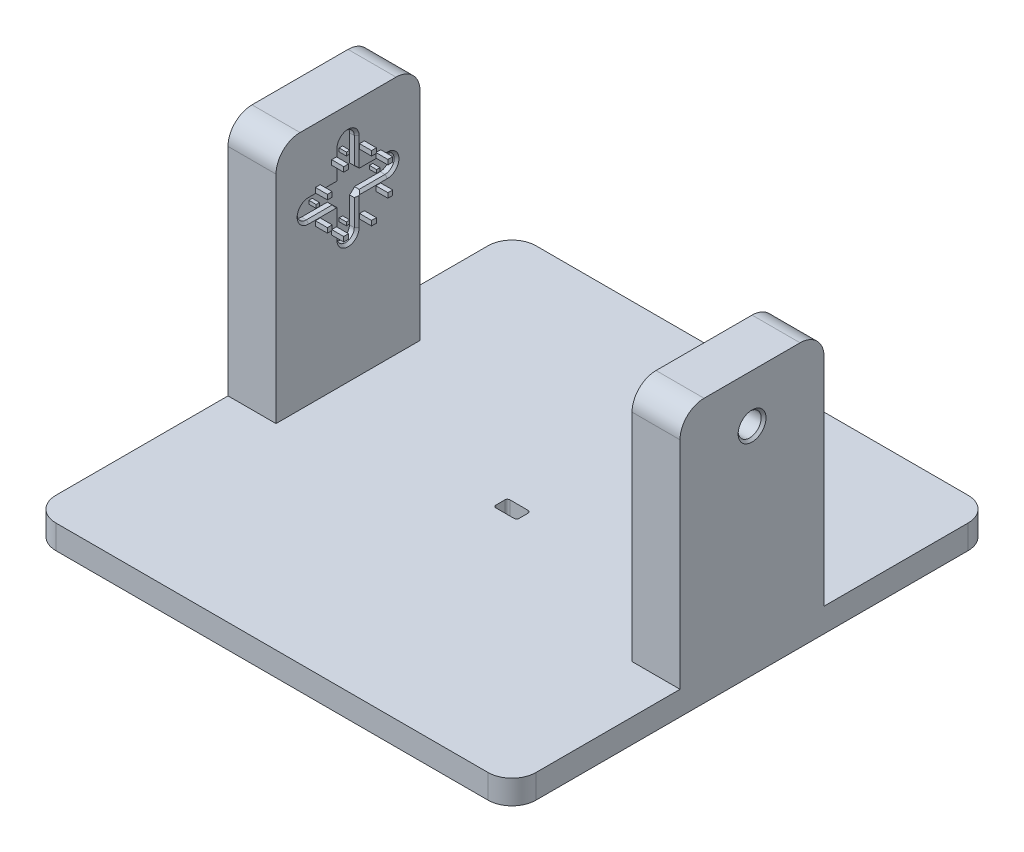
from build123d import *

# Parameters (mm, degrees)
SKETCH1_W           = 100
SKETCH1_H           = 100
BOSS_EXTRUDE1_DEPTH = 5
SKETCH2_W           = 10
SKETCH2_H           = 30
BOSS_EXTRUDE2_DEPTH = 50
CUT_EXTRUDE2_DEPTH  = 6
FILLET1_R           = 5
FILLET2_R           = 5
SKETCH7_W           = 0.707106782
SKETCH7_H           = 0.707106782
CUT_EXTRUDE3_DEPTH  = 1.5
SKETCH10_R          = 2.4
CUT_EXTRUDE4_DEPTH  = 11
CHAMFER1_SIZE       = 0.5
CHAMFER2_SIZE       = 0.5
CHAMFER3_SIZE       = 0.5
SKETCH11_W          = 1
SKETCH11_H          = 1
BOSS_EXTRUDE3_DEPTH = 2.5


with BuildPart() as part:
    # Sketch1 → Boss-Extrude1 (new body)
    with BuildSketch(Plane(origin=(0, 0, 0), x_dir=(1, 0, 0), z_dir=(0, 1, 0))):
        Rectangle(SKETCH1_W, SKETCH1_H)
    extrude(amount=BOSS_EXTRUDE1_DEPTH)

    # Sketch2 → Boss-Extrude2 (add)
    with BuildSketch(Plane(origin=(0, 5, 0), x_dir=(1, 0, 0), z_dir=(0, 1, 0))):
        with Locations((-45, 5.85)):
            Rectangle(SKETCH2_W, SKETCH2_H)
        with Locations((45, 0)):
            Rectangle(SKETCH2_W, SKETCH2_H)
    extrude(amount=BOSS_EXTRUDE2_DEPTH)

    # Sketch4 → Cut-Extrude2 (cut, through all)
    with BuildSketch(Plane(origin=(0, 5, 0), x_dir=(1, 0, 0), z_dir=(0, 1, 0))):
        with BuildLine():
            Line((-1.91, -1.46), (1.91, -1.46))
            ThreePointArc((1.91, -1.46), (2.263553391, -1.313553391), (2.41, -0.96))
            Line((2.41, -0.96), (2.41, 0.96))
            ThreePointArc((2.41, 0.96), (2.263553391, 1.313553391), (1.91, 1.46))
            Line((1.91, 1.46), (-1.91, 1.46))
            ThreePointArc((-1.91, 1.46), (-2.263553391, 1.313553391), (-2.41, 0.96))
            Line((-2.41, 0.96), (-2.41, -0.96))
            ThreePointArc((-2.41, -0.96), (-2.263553391, -1.313553391), (-1.91, -1.46))
        make_face()
    extrude(amount=-CUT_EXTRUDE2_DEPTH, mode=Mode.SUBTRACT)

    # Fillet1
    fillet1_edges = [part.edges().sort_by_distance(p)[0] for p in [
        (50, 2.5, 50),
        (-50, 2.5, 50),
        (-50, 2.5, -50),
        (50, 2.5, -50),
    ]]
    fillet(fillet1_edges, radius=FILLET1_R)

    # Fillet2
    fillet2_edges = [part.edges().sort_by_distance(p)[0] for p in [
        (-45, 55, 9.15),
        (-45, 55, -20.85),
        (45, 55, -15),
        (45, 55, 15),
    ]]
    fillet(fillet2_edges, radius=FILLET2_R)

    # Sketch7 → Cut-Extrude3 (cut)
    with BuildSketch(Plane(origin=(-40, 0, 0), x_dir=(0, 0, -1), z_dir=(1, 0, 0))):
        with BuildLine():
            Line((7.65, 31.7), (7.65, 37.11555898))
            ThreePointArc((7.65, 37.11555898), (8.211651546, 37.554064192), (8.669574436, 38.1))
            Line((8.669574436, 38.1), (14.05, 38.1))
            ThreePointArc((14.05, 38.1), (15.95, 40), (14.05, 41.9))
            Line((14.05, 41.9), (8.669574436, 41.9))
            ThreePointArc((8.669574436, 41.9), (8.211651546, 42.445935808), (7.65, 42.88444102))
            Line((7.65, 42.88444102), (7.65, 48.3))
            ThreePointArc((7.65, 48.3), (5.85, 50.1), (4.05, 48.3))
            Line((4.05, 48.3), (4.05, 42.88444102))
            ThreePointArc((4.05, 42.88444102), (3.488348454, 42.445935808), (3.030425564, 41.9))
            Line((3.030425564, 41.9), (-2.35, 41.9))
            ThreePointArc((-2.35, 41.9), (-4.25, 40), (-2.35, 38.1))
            Line((-2.35, 38.1), (3.030425564, 38.1))
            ThreePointArc((3.030425564, 38.1), (3.488348454, 37.554064192), (4.05, 37.11555898))
            Line((4.05, 37.11555898), (4.05, 31.7))
            ThreePointArc((4.05, 31.7), (5.85, 29.9), (7.65, 31.7))
        make_face()
        with Locations((-0.45, 40)):
            Rectangle(SKETCH7_W, SKETCH7_H, mode=Mode.SUBTRACT)
        with Locations((5.85, 33.7)):
            Rectangle(SKETCH7_W, SKETCH7_H, mode=Mode.SUBTRACT)
        with Locations((12.15, 40)):
            Rectangle(SKETCH7_W, SKETCH7_H, mode=Mode.SUBTRACT)
        with Locations((5.85, 46.3)):
            Rectangle(SKETCH7_W, SKETCH7_H, mode=Mode.SUBTRACT)
    extrude(amount=-CUT_EXTRUDE3_DEPTH, mode=Mode.SUBTRACT)

    # Sketch10 → Cut-Extrude4 (cut, through all)
    with BuildSketch(Plane.ZY.offset(-40)):
        with Locations((0, 45)):
            Circle(SKETCH10_R)
    extrude(amount=-CUT_EXTRUDE4_DEPTH, mode=Mode.SUBTRACT)

    # Chamfer1
    chamfer1_edges = [part.edges().sort_by_distance(p)[0] for p in [
        (2.263553391, 0, 1.313553391),
        (0, 0, 1.46),
        (-2.263553391, 0, 1.313553391),
        (-2.41, 0, 0),
        (-2.263553391, 0, -1.313553391),
        (0, 0, -1.46),
        (2.263553391, 0, -1.313553391),
        (2.41, 0, 0),
    ]]
    chamfer(chamfer1_edges, length=CHAMFER1_SIZE)

    # Chamfer2
    chamfer2_edges = [part.edges().sort_by_distance(p)[0] for p in [
        (-40, 45.59222051, -4.05),
        (-40, 41.9, -11.359787218),
        (-40, 34.40777949, -4.05),
        (-40, 41.9, -0.340212782),
        (-40, 40, 4.25),
        (-40, 38.1, -0.340212782),
        (-40, 29.9, -5.85),
        (-40, 34.40777949, -7.65),
        (-40, 38.1, -11.359787218),
        (-40, 40, -15.95),
        (-40, 45.59222051, -7.65),
        (-40, 50.1, -5.85),
    ]]
    chamfer(chamfer2_edges, length=CHAMFER2_SIZE)

    # Chamfer3
    chamfer3_edges = [part.edges().sort_by_distance(p)[0] for p in [
        (50, 45, -2.4),
    ]]
    chamfer(chamfer3_edges, length=CHAMFER3_SIZE)

    # Sketch11 → Boss-Extrude3 (add)
    with BuildSketch(Plane(origin=(-40, 0, 0), x_dir=(0, 0, -1), z_dir=(1, 0, 0))):
        with Locations((2.95, 46.3)):
            Rectangle(SKETCH11_W, SKETCH11_H)
        with Locations((8.75, 46.3)):
            Rectangle(SKETCH11_W, SKETCH11_H)
        with Locations((12.15, 43)):
            Rectangle(SKETCH11_W, SKETCH11_H)
        with Locations((12.15, 37)):
            Rectangle(SKETCH11_W, SKETCH11_H)
        with Locations((8.75, 33.7)):
            Rectangle(SKETCH11_W, SKETCH11_H)
        with Locations((2.95, 33.7)):
            Rectangle(SKETCH11_W, SKETCH11_H)
        with Locations((-0.45, 37)):
            Rectangle(SKETCH11_W, SKETCH11_H)
        with Locations((-0.45, 43)):
            Rectangle(SKETCH11_W, SKETCH11_H)
    extrude(amount=BOSS_EXTRUDE3_DEPTH)


solid = part.part
